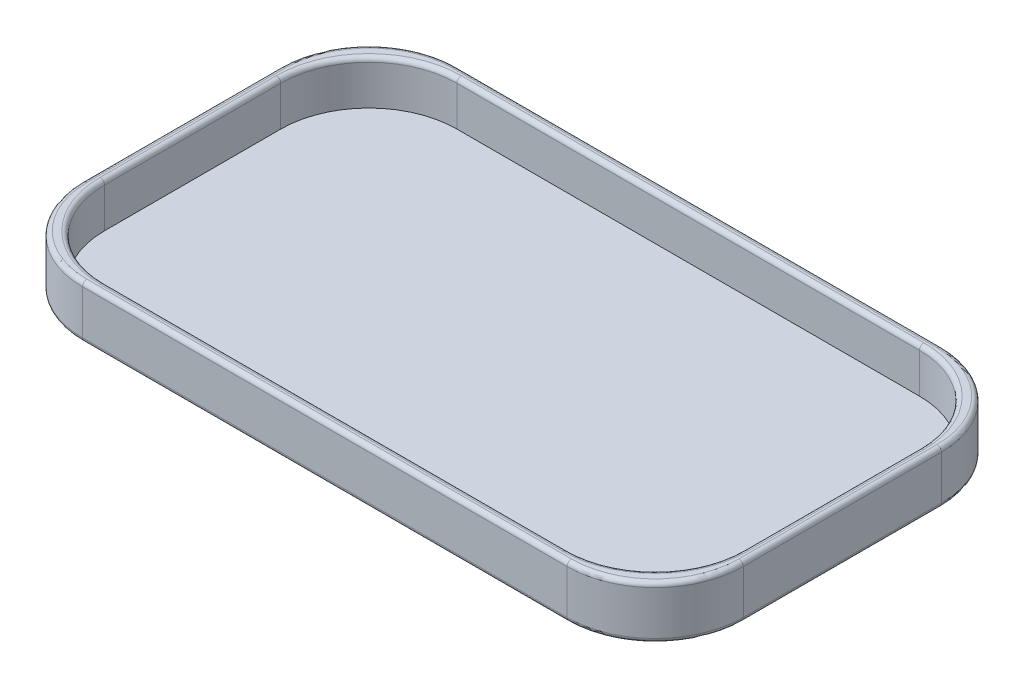
from build123d import *

# Parameters (mm, degrees)
SKETCH1_W           = 150
SKETCH1_H           = 85
BOSS_EXTRUDE1_DEPTH = 2
SKETCH2_W           = 150
SKETCH2_H           = 85
SKETCH2_W_2         = 145
SKETCH2_H_2         = 80
BOSS_EXTRUDE2_DEPTH = 10
FILLET1_R           = 20
FILLET2_R           = 1


with BuildPart() as part:
    # Sketch1 → Boss-Extrude1 (new body)
    with BuildSketch(Plane(origin=(0, 0, 0), x_dir=(1, 0, 0), z_dir=(0, 1, 0))):
        Rectangle(SKETCH1_W, SKETCH1_H)
    extrude(amount=BOSS_EXTRUDE1_DEPTH)

    # Sketch2 → Boss-Extrude2 (add)
    with BuildSketch(Plane(origin=(0, 2, 0), x_dir=(1, 0, 0), z_dir=(0, 1, 0))):
        Rectangle(SKETCH2_W, SKETCH2_H)
        Rectangle(SKETCH2_W_2, SKETCH2_H_2, mode=Mode.SUBTRACT)
    extrude(amount=BOSS_EXTRUDE2_DEPTH)

    # Fillet1
    fillet1_edges = [part.edges().sort_by_distance(p)[0] for p in [
        (72.5, 7, -40),
        (-72.5, 7, -40),
        (-72.5, 7, 40),
        (72.5, 7, 40),
        (75, 6, 42.5),
        (-75, 6, 42.5),
        (-75, 6, -42.5),
        (75, 6, -42.5),
    ]]
    fillet(fillet1_edges, radius=FILLET1_R)

    # Fillet2
    fillet2_edges = [part.edges().sort_by_distance(p)[0] for p in [
        (0, 0, -42.5),
        (0, 12, -42.5),
        (75, 0, 0),
        (0, 0, 42.5),
        (-75, 0, 0),
        (-69.142135624, 0, -36.642135624),
        (-69.142135624, 0, 36.642135624),
        (69.142135624, 0, 36.642135624),
        (69.142135624, 0, -36.642135624),
        (75, 12, 0),
        (0, 12, 42.5),
        (-75, 12, 0),
        (-72.5, 12, 0),
        (0, 12, 40),
        (72.5, 12, 0),
        (0, 12, -40),
        (-66.642135624, 12, 34.142135624),
        (66.642135624, 12, 34.142135624),
        (66.642135624, 12, -34.142135624),
        (-66.642135624, 12, -34.142135624),
        (-69.142135624, 12, -36.642135624),
        (-69.142135624, 12, 36.642135624),
        (69.142135624, 12, 36.642135624),
        (69.142135624, 12, -36.642135624),
    ]]
    fillet(fillet2_edges, radius=FILLET2_R)


solid = part.part
